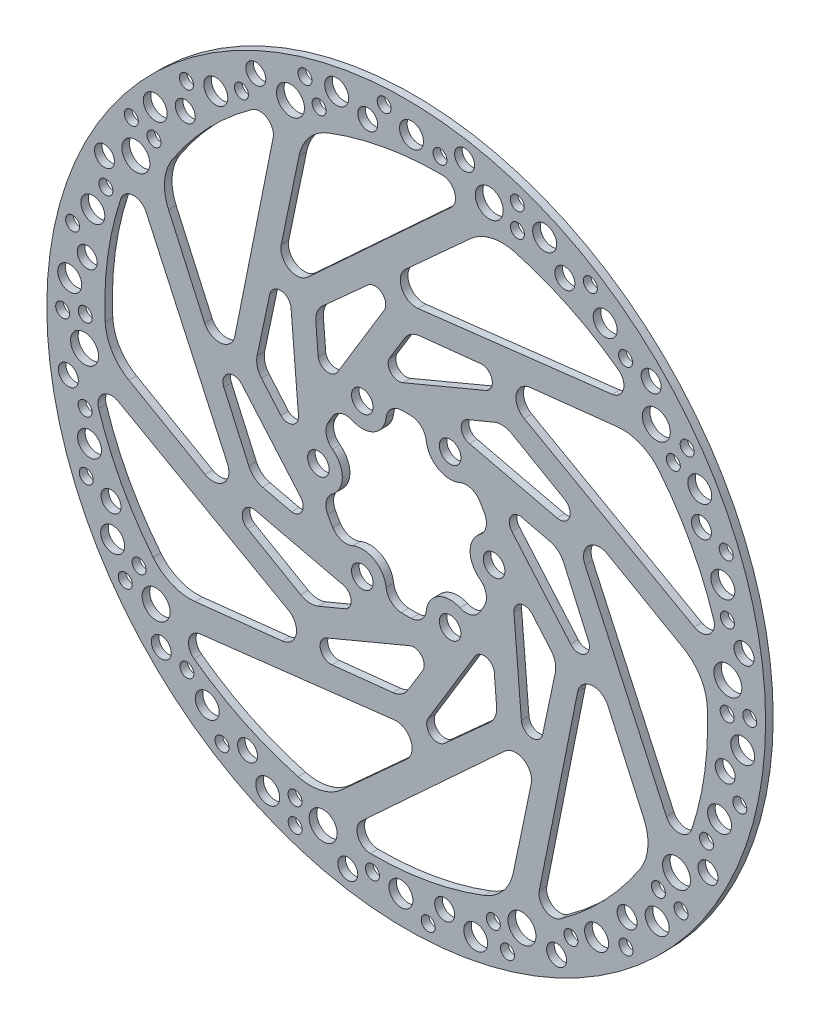
from build123d import *

# Parameters (mm, degrees)
SKETCH5_R          = 90
EXTRUDE2_DEPTH     = 1.9
SKETCH2_R          = 3.5
SKETCH2_R_2        = 3
SKETCH2_R_3        = 1.75
SKETCH2_R_4        = 2.5
CUT_EXTRUDE5_DEPTH = 1.9
CIRPATTERN3_COUNT  = 10
CUT_EXTRUDE6_DEPTH = 1.9
CIRPATTERN4_COUNT  = 6


with BuildPart() as part:
    # Sketch5 → Extrude2 (new body)
    with BuildSketch(Plane.XY):
        Circle(SKETCH5_R)
    extrude(amount=EXTRUDE2_DEPTH)

    # Sketch2 → Cut-Extrude5 (cut)
    with BuildSketch(Plane.XY):
        with Locations((-28.98271508, 75.269681644)):
            Circle(SKETCH2_R)
        with Locations((-17.406449341, 82.942133628)):
            Circle(SKETCH2_R_2)
        with Locations((-25.355219141, 82.210139864)):
            Circle(SKETCH2_R_3)
        with Locations((-21.814239494, 77.414781937)):
            Circle(SKETCH2_R_3)
        with Locations((-9.632865772, 80.854479516)):
            Circle(SKETCH2_R_4)
        with Locations((-5.515915401, 86.037742916)):
            Circle(SKETCH2_R_3)
        with Locations((1.330183297, 82.942133628)):
            Circle(SKETCH2_R_2)
        with Locations((8.451983073, 81.817375701)):
            Circle(SKETCH2_R_3)
        with Locations((14.626141715, 84.203130815)):
            Circle(SKETCH2_R_4)
        with BuildLine():
            Line((-21.002195413, 34.617877635), (-9.632865772, 44.875919417))
            ThreePointArc((-9.632865772, 44.875919417), (-6.102754959, 44.951591184), (-5.515915401, 41.469777303))
            Line((-5.515915401, 41.469777303), (-17.211008504, 22.2071468))
            ThreePointArc((-17.211008504, 22.2071468), (-19.910234369, 20.979650084), (-22.039259353, 23.043583483))
            Line((-22.039259353, 23.043583483), (-22.638189095, 30.501586927))
            ThreePointArc((-22.638189095, 30.501586927), (-22.300395617, 32.750586067), (-21.002195413, 34.617877635))
        make_face()
        with BuildLine():
            Line((11.243221475, 72.157831904), (-24.677288852, 39.048927805))
            ThreePointArc((-24.677288852, 39.048927805), (-29.360662453, 38.510223187), (-31.304365463, 42.805128256))
            Line((-31.304365463, 42.805128256), (-26.83299597, 64.290063053))
            ThreePointArc((-26.83299597, 64.290063053), (-24.252761504, 69.555593676), (-19.460938602, 72.935217312))
            ThreePointArc((-19.460938602, 72.935217312), (-5.4902953, 76.820606493), (8.956820179, 78.067994843))
            ThreePointArc((8.956820179, 78.067994843), (12.111378224, 75.891025619), (11.243221475, 72.157831904))
        make_face()
    cut_extrude5 = extrude(amount=CUT_EXTRUDE5_DEPTH, mode=Mode.SUBTRACT)

    # CirPattern3: Cut-Extrude5 ×10 about axis
    cirpattern3_axis = Axis((0, 0, 0), (0, 0, 1))
    for i in range(1, CIRPATTERN3_COUNT):
        add(cut_extrude5.rotate(cirpattern3_axis, i * 360 / CIRPATTERN3_COUNT), mode=Mode.SUBTRACT)

    # Sketch4 → Cut-Extrude6 (cut)
    with BuildSketch(Plane.XY):
        with BuildLine():
            ThreePointArc((-13.419207132, 13.561890722), (-8, 13.856406461), (-5.035338323, 18.402319636))
            ThreePointArc((-5.035338323, 18.402319636), (-3.816135855, 20.866694128), (-1.294207695, 21.961899427))
            ThreePointArc((-1.294207695, 21.961899427), (-0.6473842, 21.990472794), (0, 22))
            ThreePointArc((0, 22), (0.6473842, 21.990472794), (1.294207695, 21.961899427))
            ThreePointArc((1.294207695, 21.961899427), (3.816135855, 20.866694128), (5.035338323, 18.402319636))
            ThreePointArc((5.035338323, 18.402319636), (8, 13.856406461), (13.419207132, 13.561890722))
            ThreePointArc((13.419207132, 13.561890722), (16.16301928, 13.738217659), (18.372458972, 12.101766455))
            ThreePointArc((18.372458972, 12.101766455), (18.720615981, 11.55588756), (19.052558883, 11))
            ThreePointArc((19.052558883, 11), (19.368000181, 10.434585233), (19.666666667, 9.860132972))
            ThreePointArc((19.666666667, 9.860132972), (19.979155135, 7.128476469), (18.454545455, 4.840428913))
            ThreePointArc((18.454545455, 4.840428913), (16, 0), (18.454545455, -4.840428913))
            ThreePointArc((18.454545455, -4.840428913), (19.979155135, -7.128476469), (19.666666667, -9.860132972))
            ThreePointArc((19.666666667, -9.860132972), (19.368000181, -10.434585233), (19.052558883, -11))
            ThreePointArc((19.052558883, -11), (18.720615981, -11.55588756), (18.372458972, -12.101766455))
            ThreePointArc((18.372458972, -12.101766455), (16.16301928, -13.738217659), (13.419207132, -13.561890722))
            ThreePointArc((13.419207132, -13.561890722), (8, -13.856406461), (5.035338323, -18.402319636))
            ThreePointArc((5.035338323, -18.402319636), (3.816135855, -20.866694128), (1.294207695, -21.961899427))
            ThreePointArc((1.294207695, -21.961899427), (0.6473842, -21.990472794), (0, -22))
            ThreePointArc((0, -22), (-0.6473842, -21.990472794), (-1.294207695, -21.961899427))
            ThreePointArc((-1.294207695, -21.961899427), (-3.816135855, -20.866694128), (-5.035338323, -18.402319636))
            ThreePointArc((-5.035338323, -18.402319636), (-8, -13.856406461), (-13.419207132, -13.561890722))
            ThreePointArc((-13.419207132, -13.561890722), (-16.16301928, -13.738217659), (-18.372458972, -12.101766455))
            ThreePointArc((-18.372458972, -12.101766455), (-18.720615981, -11.55588756), (-19.052558883, -11))
            ThreePointArc((-19.052558883, -11), (-19.368000181, -10.434585233), (-19.666666667, -9.860132972))
            ThreePointArc((-19.666666667, -9.860132972), (-19.979155135, -7.128476469), (-18.454545455, -4.840428913))
            ThreePointArc((-18.454545455, -4.840428913), (-16, 0), (-18.454545455, 4.840428913))
            ThreePointArc((-18.454545455, 4.840428913), (-19.979155135, 7.128476469), (-19.666666667, 9.860132972))
            ThreePointArc((-19.666666667, 9.860132972), (-19.368000181, 10.434585233), (-19.052558883, 11))
            ThreePointArc((-19.052558883, 11), (-18.720615981, 11.55588756), (-18.372458972, 12.101766455))
            ThreePointArc((-18.372458972, 12.101766455), (-16.16301928, 13.738217659), (-13.419207132, 13.561890722))
        make_face()
    extrude(amount=CUT_EXTRUDE6_DEPTH, mode=Mode.SUBTRACT)

    # Sketch6 → Ø5.4 (5.4) Diameter Hole1 (revolve, cut)
    with BuildSketch(Plane(origin=(-11, 19.052558883, 0), x_dir=(0, 1, 0), z_dir=(1, 0, 0))):
        Polygon((0, 0), (0, 6.622323671), (2.7, 5), (2.7, 0), align=None)
    f_5_4_5_4_diameter_hole1 = revolve(axis=Axis((-11, 19.052558883, -6.35), (0, 0, 1)), mode=Mode.SUBTRACT)

    # CirPattern4: Ø5.4 (5.4) Diameter Hole1 ×6 about axis
    cirpattern4_axis = Axis((0, 0, 0), (0, 0, 1))
    for i in range(1, CIRPATTERN4_COUNT):
        add(f_5_4_5_4_diameter_hole1.rotate(cirpattern4_axis, i * 360 / CIRPATTERN4_COUNT), mode=Mode.SUBTRACT)


solid = part.part
